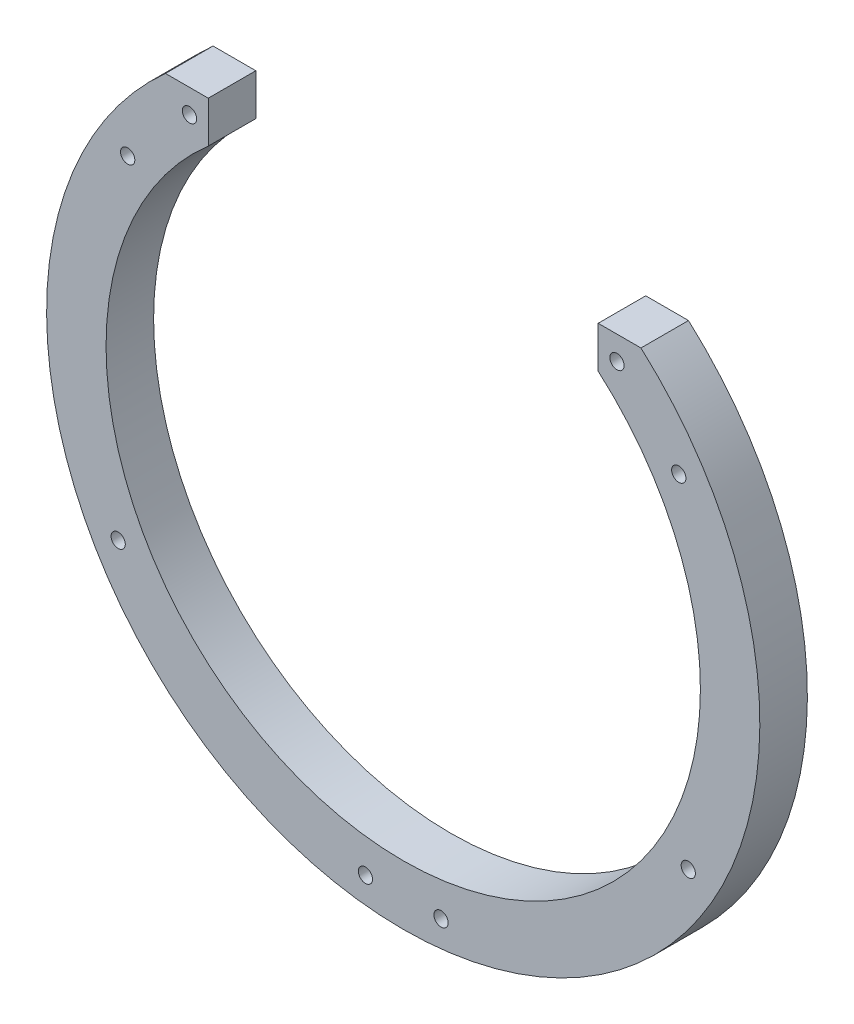
from build123d import *

# Parameters (mm, degrees)
RESSALTO_EXTRUS_O1_DEPTH = 10
ESBO_O2_R                = 1.5
CORTE_EXTRUS_O1_DEPTH    = 10
ESBO_O3_W                = 82
ESBO_O3_H                = 21.575786581
CORTE_EXTRUS_O2_DEPTH    = 11


with BuildPart() as part:
    # Esboço1 → Ressalto-extrusão1 (new body)
    with BuildSketch(Plane.XY):
        with BuildLine():
            Line((44.495405461, -168.430491325), (22.44625518, -168.430491325))
            ThreePointArc((22.44625518, -168.430491325), (-5.504594539, -286.832190763), (-33.455444258, -168.430491325))
            Line((-33.455444258, -168.430491325), (-55.504594539, -168.430491325))
            ThreePointArc((-55.504594539, -168.430491325), (-5.504594539, -299.332190763), (44.495405461, -168.430491325))
        make_face()
    extrude(amount=RESSALTO_EXTRUS_O1_DEPTH)

    # Esboço2 → Corte-extrusão1 (cut)
    with BuildSketch(Plane.XY.offset(10)):
        with Locations((39.44625518, -173.430491325)):
            Circle(ESBO_O2_R)
        with Locations((52.44625518, -187.430491325)):
            Circle(ESBO_O2_R)
        with Locations((54.44625518, -258.430491325)):
            Circle(ESBO_O2_R)
        with Locations((-13.455444258, -293.430491325)):
            Circle(ESBO_O2_R)
        with Locations((2.44625518, -293.430491325)):
            Circle(ESBO_O2_R)
        with Locations((-65.455444258, -258.430491325)):
            Circle(ESBO_O2_R)
        with Locations((-63.455444258, -187.430491325)):
            Circle(ESBO_O2_R)
        with Locations((-50.455444258, -173.430491325)):
            Circle(ESBO_O2_R)
    extrude(amount=-CORTE_EXTRUS_O1_DEPTH, mode=Mode.SUBTRACT)

    # Esboço3 → Corte-extrusão2 (cut, through all)
    with BuildSketch(Plane.XY.offset(10)):
        with Locations((-5.504594539, -170.044523075)):
            Rectangle(ESBO_O3_W, ESBO_O3_H)
    extrude(amount=-CORTE_EXTRUS_O2_DEPTH, mode=Mode.SUBTRACT)


solid = part.part
